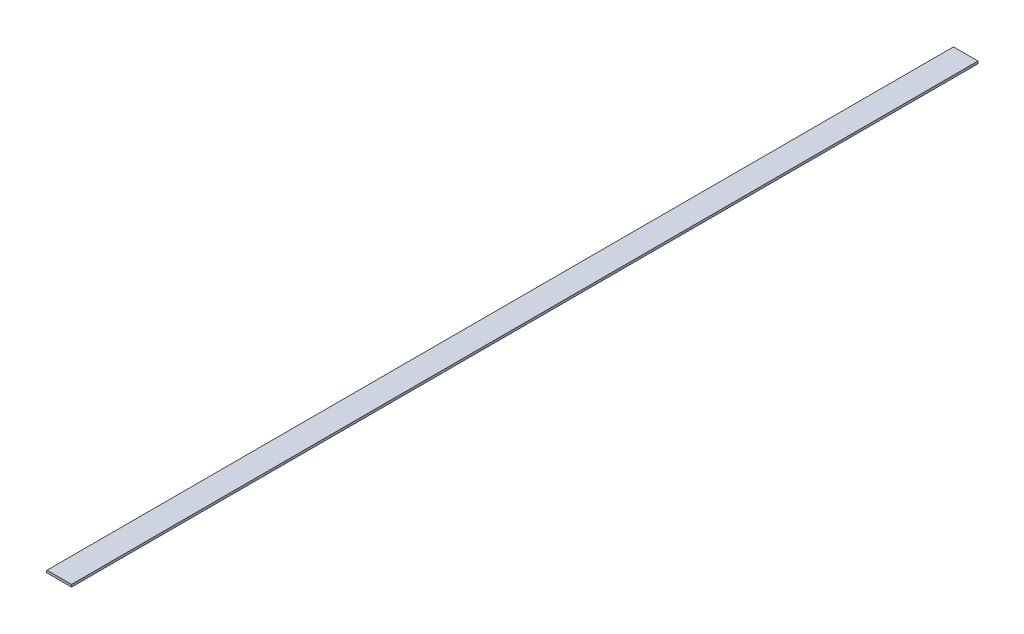
from build123d import *

# Parameters (mm, degrees)
BOSS_EXTRUDE1_DEPTH = 901.7


with BuildPart() as part:
    # Sketch1 → Boss-Extrude1 (new body)
    with BuildSketch(Plane.XY):
        Polygon((0, 0), (25.4, 0), (25.4, 2.3622), (0.978455277, 2.3622), align=None)
    extrude(amount=BOSS_EXTRUDE1_DEPTH)


solid = part.part
